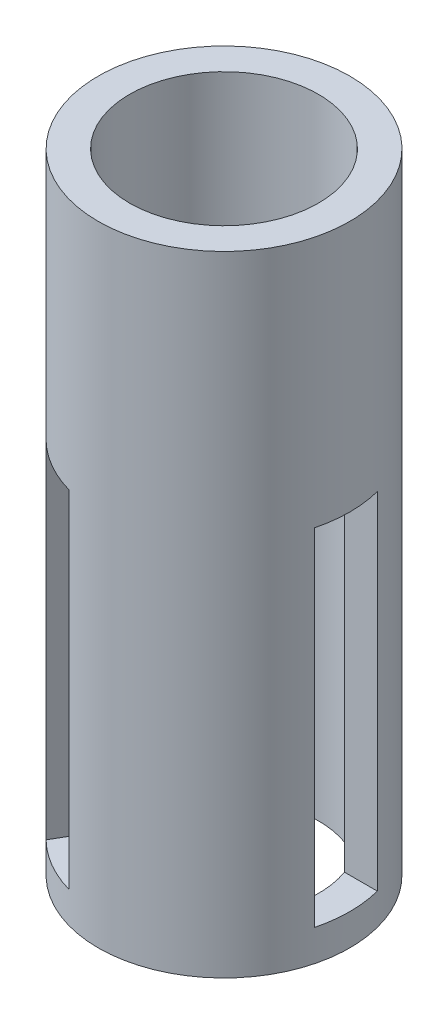
from build123d import *

# Parameters (mm, degrees)
SKETCH1_R           = 20
SKETCH1_R_2         = 15
BOSS_EXTRUDE1_DEPTH = 100
SKETCH2_W           = 10
SKETCH2_H           = 55
CUT_EXTRUDE2_DEPTH  = 5.857864
CIRPATTERN1_COUNT   = 3


with BuildPart() as part:
    # Sketch1 → Boss-Extrude1 (new body)
    with BuildSketch(Plane(origin=(0, 0, 0), x_dir=(1, 0, 0), z_dir=(0, 1, 0))):
        Circle(SKETCH1_R)
        Circle(SKETCH1_R_2, mode=Mode.SUBTRACT)
    extrude(amount=BOSS_EXTRUDE1_DEPTH)

    # Sketch2 → Cut-Extrude2 (cut)
    with BuildSketch(Plane(origin=(20, 0, 0), x_dir=(0, 0, -1), z_dir=(1, 0, 0))):
        with Locations((0, 32.5)):
            Rectangle(SKETCH2_W, SKETCH2_H)
    cut_extrude2 = extrude(amount=-CUT_EXTRUDE2_DEPTH, mode=Mode.SUBTRACT)

    # CirPattern1: Cut-Extrude2 ×3 about axis
    cirpattern1_axis = Axis((0, 0, 0), (0, 1, 0))
    for i in range(1, CIRPATTERN1_COUNT):
        add(cut_extrude2.rotate(cirpattern1_axis, i * 360 / CIRPATTERN1_COUNT), mode=Mode.SUBTRACT)


solid = part.part
